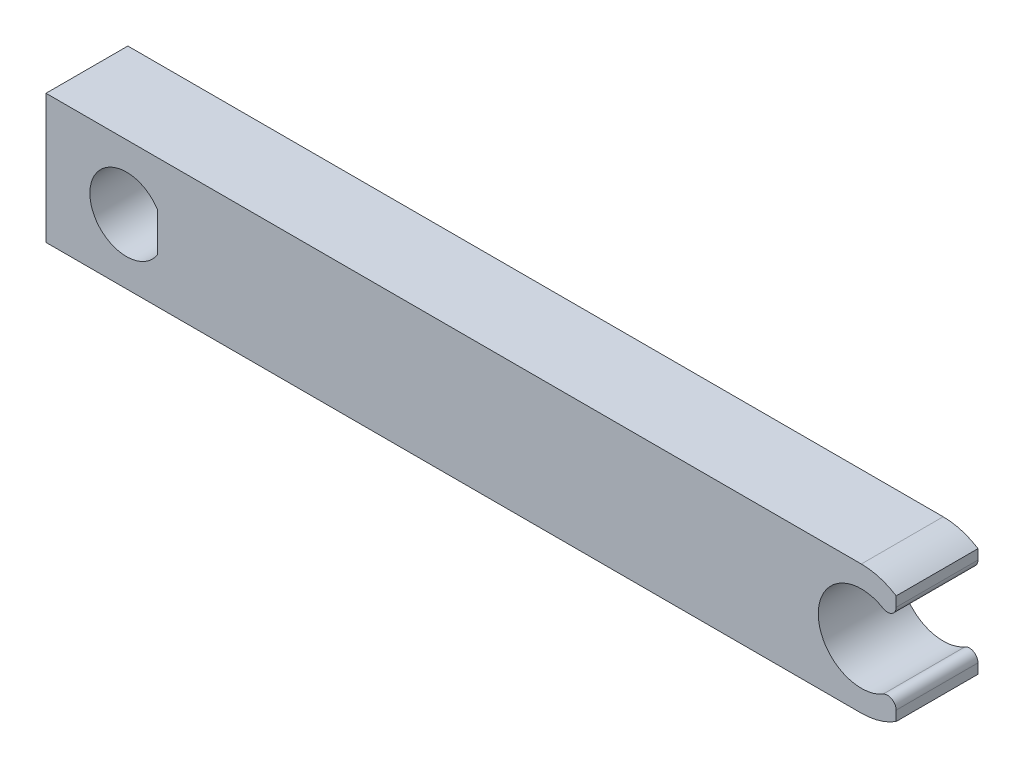
from build123d import *

# Parameters (mm, degrees)
SKETCH_1_R      = 3.4
EXTRUDE_2_DEPTH = 7.6
SKETCH_2_W      = 6.529029983
SKETCH_2_H      = 6.008592339
EXTRUDE_5_DEPTH = 7.5
FILLET_1_R      = 0.8


with BuildPart() as part:
    # 草图1 → 凸台-拉伸2 (new body)
    with BuildSketch(Plane.XY):
        with BuildLine():
            Line((53.915690558, 12), (-21.801891992, 12))
            Line((-21.801891992, 12), (-21.801891992, 0))
            Line((-21.801891992, 0), (53.915690558, 0))
            ThreePointArc((53.915690558, 0), (55.600804493, 0.241494028), (57.150270111, 0.946536325))
            Line((57.150270111, 0.946536325), (57.150270111, 3.646811713))
            ThreePointArc((57.150270111, 3.646811713), (49.915690558, 6), (57.150270111, 8.353188287))
            Line((57.150270111, 8.353188287), (57.150270111, 11.053463675))
            ThreePointArc((57.150270111, 11.053463675), (55.600804493, 11.758505972), (53.915690558, 12))
        make_face()
        with Locations((-14.326955942, 6)):
            Circle(SKETCH_1_R, mode=Mode.SUBTRACT)
    extrude(amount=EXTRUDE_2_DEPTH)

    # 草图2 → 凸台-拉伸5 (add)
    with BuildSketch(Plane.XY.offset(7.6)):
        with Locations((-8.162440951, 7.229472235)):
            Rectangle(SKETCH_2_W, SKETCH_2_H)
    extrude(amount=-EXTRUDE_5_DEPTH)

    # 圆角1
    fillet_1_edges = [part.edges().sort_by_distance(p)[0] for p in [
        (57.150270111, 8.353188287, 3.8),
        (57.150270111, 3.646811713, 3.8),
    ]]
    fillet(fillet_1_edges, radius=FILLET_1_R)


solid = part.part
